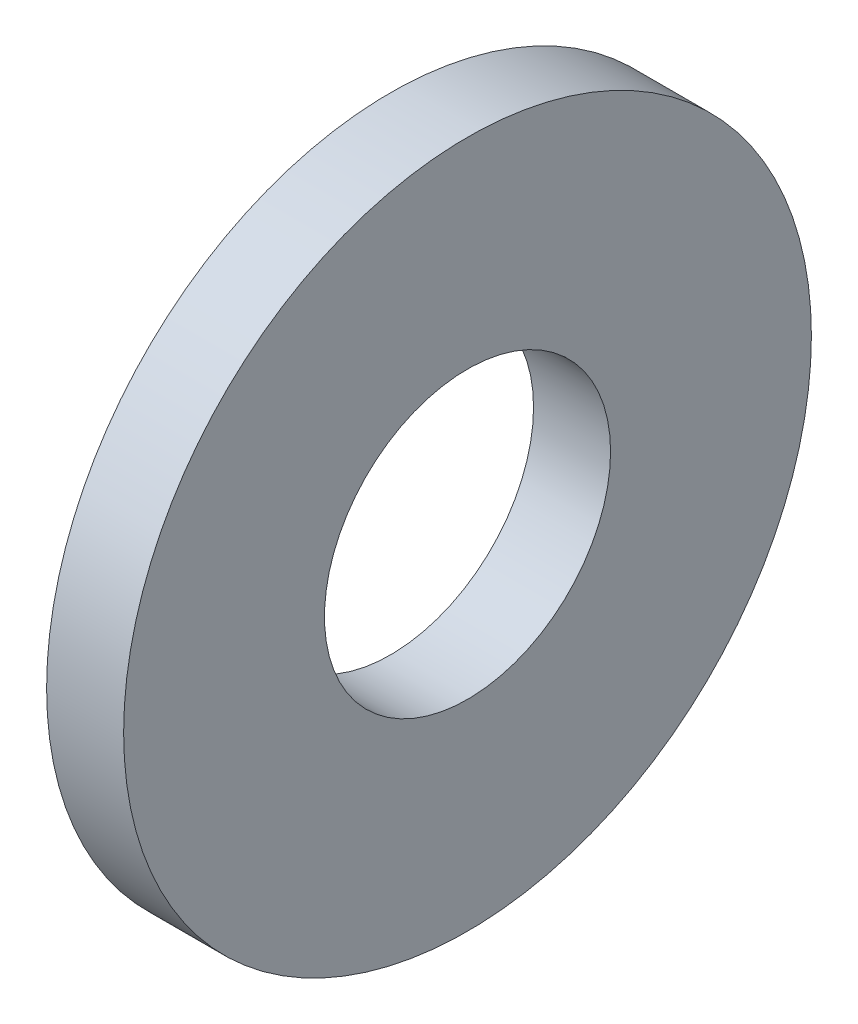
from build123d import *

# Parameters (mm, degrees)
SKETCH1_R           = 7.9375
SKETCH1_R_2         = 3.302
BOSS_EXTRUDE1_DEPTH = 1.778


with BuildPart() as part:
    # Sketch1 → Boss-Extrude1 (new body)
    with BuildSketch(Plane(origin=(0, 0, 0), x_dir=(0, 0, -1), z_dir=(1, 0, 0))):
        Circle(SKETCH1_R)
        Circle(SKETCH1_R_2, mode=Mode.SUBTRACT)
    extrude(amount=BOSS_EXTRUDE1_DEPTH)


solid = part.part
